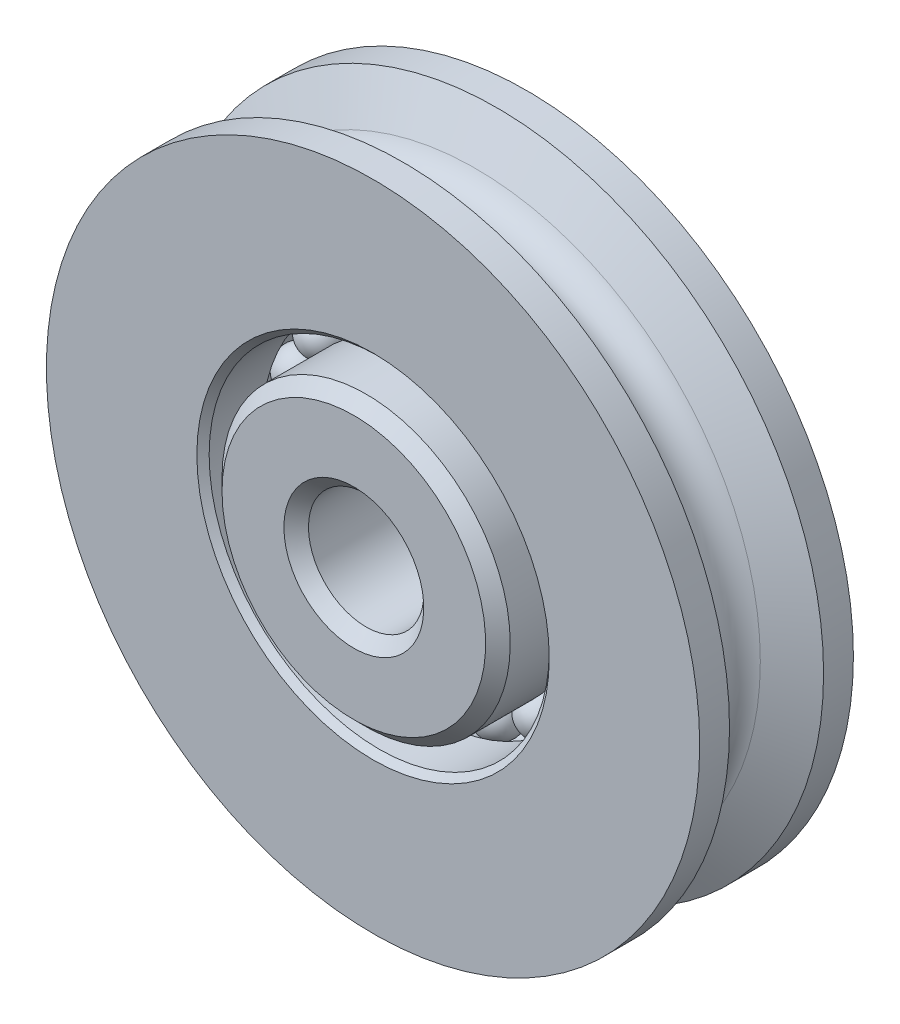
from build123d import *

# Parameters (mm, degrees)
CIRPATTERN1_COUNT = 20
CHAMFER1_SIZE     = 0.508
CHAMFER2_SIZE     = 0.254


with BuildPart() as part:
    # Sketch1 → Revolve1 (revolve)
    with BuildSketch(Plane(origin=(0, 0, 0), x_dir=(0, 0, -1), z_dir=(1, 0, 0))):
        with BuildLine():
            Line((1.9431, 13.49375), (3.175, 13.49375))
            Line((3.175, 13.49375), (3.175, 7.0246875))
            Line((3.175, 7.0246875), (0.714375, 7.0246875))
            ThreePointArc((0.714375, 7.0246875), (0, 7.381875), (-0.714375, 7.0246875))
            Line((-0.714375, 7.0246875), (-3.175, 7.0246875))
            Line((-3.175, 7.0246875), (-3.175, 13.49375))
            Line((-3.175, 13.49375), (-1.9431, 13.49375))
            Line((-1.9431, 13.49375), (-1.06081087, 11.76250666))
            ThreePointArc((-1.06081087, 11.76250666), (0, 11.1125), (1.06081087, 11.76250666))
            Line((1.06081087, 11.76250666), (1.9431, 13.49375))
        make_face()
        with BuildLine():
            Line((3.96875, 2.38125), (-3.96875, 2.38125))
            Line((-3.96875, 2.38125), (-3.96875, 5.953125))
            Line((-3.96875, 5.953125), (-0.714375, 5.953125))
            ThreePointArc((-0.714375, 5.953125), (0, 5.5959375), (0.714375, 5.953125))
            Line((0.714375, 5.953125), (3.96875, 5.953125))
            Line((3.96875, 5.953125), (3.96875, 2.38125))
        make_face()
    revolve(axis=Axis((0, 0, 3.96875), (0, 0, -1)))

    # Chamfer1
    chamfer1_edges = [part.edges().sort_by_distance(p)[0] for p in [
        (0, -5.953125, 3.96875),
        (0, -5.953125, -3.96875),
        (0, -2.38125, -3.96875),
        (0, -2.38125, 3.96875),
    ]]
    chamfer(chamfer1_edges, length=CHAMFER1_SIZE)

    # Chamfer2
    chamfer2_edges = [part.edges().sort_by_distance(p)[0] for p in [
        (0, -7.0246875, -3.175),
        (0, -7.0246875, 3.175),
    ]]
    chamfer(chamfer2_edges, length=CHAMFER2_SIZE)


with BuildPart() as body_2:
    # Sketch2 → Revolve2 (revolve)
    with BuildSketch(Plane(origin=(0, 0, 0), x_dir=(0, 0, -1), z_dir=(1, 0, 0))):
        with BuildLine():
            Line((0, 7.381875), (0, 5.5959375))
            ThreePointArc((0, 5.5959375), (0.89296875, 6.48890625), (0, 7.381875))
        make_face()
    revolve(axis=Axis((0, 7.381875, 0), (0, -1, 0)))


with BuildPart() as cirpattern1_1:
    # CirPattern1: pattern copy
    add(body_2.part.rotate(Axis((0, 0, 0), (0, 0, 1)), 1 * 360 / CIRPATTERN1_COUNT))


with BuildPart() as cirpattern1_2:
    # CirPattern1: pattern copy
    add(body_2.part.rotate(Axis((0, 0, 0), (0, 0, 1)), 2 * 360 / CIRPATTERN1_COUNT))


with BuildPart() as cirpattern1_3:
    # CirPattern1: pattern copy
    add(body_2.part.rotate(Axis((0, 0, 0), (0, 0, 1)), 3 * 360 / CIRPATTERN1_COUNT))


with BuildPart() as cirpattern1_4:
    # CirPattern1: pattern copy
    add(body_2.part.rotate(Axis((0, 0, 0), (0, 0, 1)), 4 * 360 / CIRPATTERN1_COUNT))


with BuildPart() as cirpattern1_5:
    # CirPattern1: pattern copy
    add(body_2.part.rotate(Axis((0, 0, 0), (0, 0, 1)), 5 * 360 / CIRPATTERN1_COUNT))


with BuildPart() as cirpattern1_6:
    # CirPattern1: pattern copy
    add(body_2.part.rotate(Axis((0, 0, 0), (0, 0, 1)), 6 * 360 / CIRPATTERN1_COUNT))


with BuildPart() as cirpattern1_7:
    # CirPattern1: pattern copy
    add(body_2.part.rotate(Axis((0, 0, 0), (0, 0, 1)), 7 * 360 / CIRPATTERN1_COUNT))


with BuildPart() as cirpattern1_8:
    # CirPattern1: pattern copy
    add(body_2.part.rotate(Axis((0, 0, 0), (0, 0, 1)), 8 * 360 / CIRPATTERN1_COUNT))


with BuildPart() as cirpattern1_9:
    # CirPattern1: pattern copy
    add(body_2.part.rotate(Axis((0, 0, 0), (0, 0, 1)), 9 * 360 / CIRPATTERN1_COUNT))


with BuildPart() as cirpattern1_10:
    # CirPattern1: pattern copy
    add(body_2.part.rotate(Axis((0, 0, 0), (0, 0, 1)), 10 * 360 / CIRPATTERN1_COUNT))


with BuildPart() as cirpattern1_11:
    # CirPattern1: pattern copy
    add(body_2.part.rotate(Axis((0, 0, 0), (0, 0, 1)), 11 * 360 / CIRPATTERN1_COUNT))


with BuildPart() as cirpattern1_12:
    # CirPattern1: pattern copy
    add(body_2.part.rotate(Axis((0, 0, 0), (0, 0, 1)), 12 * 360 / CIRPATTERN1_COUNT))


with BuildPart() as cirpattern1_13:
    # CirPattern1: pattern copy
    add(body_2.part.rotate(Axis((0, 0, 0), (0, 0, 1)), 13 * 360 / CIRPATTERN1_COUNT))


with BuildPart() as cirpattern1_14:
    # CirPattern1: pattern copy
    add(body_2.part.rotate(Axis((0, 0, 0), (0, 0, 1)), 14 * 360 / CIRPATTERN1_COUNT))


with BuildPart() as cirpattern1_15:
    # CirPattern1: pattern copy
    add(body_2.part.rotate(Axis((0, 0, 0), (0, 0, 1)), 15 * 360 / CIRPATTERN1_COUNT))


with BuildPart() as cirpattern1_16:
    # CirPattern1: pattern copy
    add(body_2.part.rotate(Axis((0, 0, 0), (0, 0, 1)), 16 * 360 / CIRPATTERN1_COUNT))


with BuildPart() as cirpattern1_17:
    # CirPattern1: pattern copy
    add(body_2.part.rotate(Axis((0, 0, 0), (0, 0, 1)), 17 * 360 / CIRPATTERN1_COUNT))


with BuildPart() as cirpattern1_18:
    # CirPattern1: pattern copy
    add(body_2.part.rotate(Axis((0, 0, 0), (0, 0, 1)), 18 * 360 / CIRPATTERN1_COUNT))


with BuildPart() as cirpattern1_19:
    # CirPattern1: pattern copy
    add(body_2.part.rotate(Axis((0, 0, 0), (0, 0, 1)), 19 * 360 / CIRPATTERN1_COUNT))


solid = Compound([part.part, body_2.part, cirpattern1_1.part, cirpattern1_2.part, cirpattern1_3.part, cirpattern1_4.part, cirpattern1_5.part, cirpattern1_6.part, cirpattern1_7.part, cirpattern1_8.part, cirpattern1_9.part, cirpattern1_10.part, cirpattern1_11.part, cirpattern1_12.part, cirpattern1_13.part, cirpattern1_14.part, cirpattern1_15.part, cirpattern1_16.part, cirpattern1_17.part, cirpattern1_18.part, cirpattern1_19.part])
